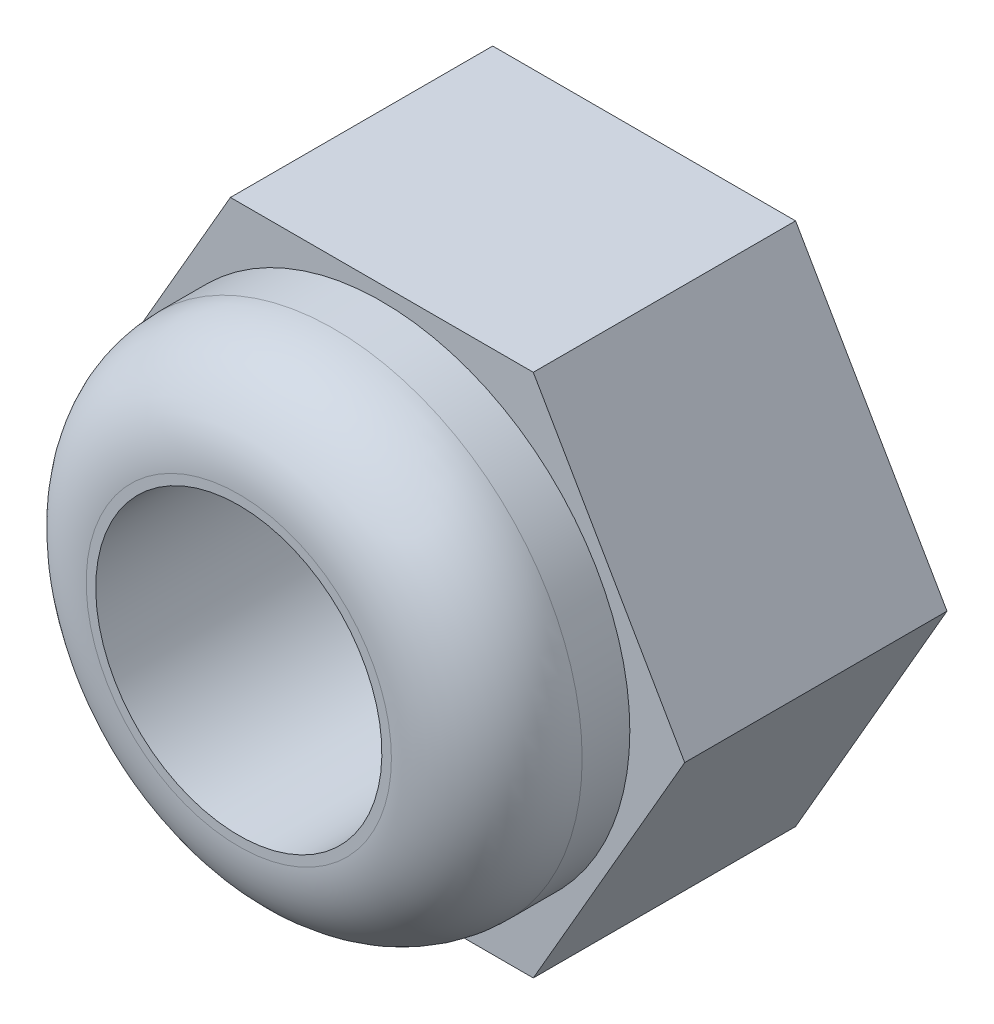
from build123d import *

# Parameters (mm, degrees)
EXTRUDE_1_DEPTH           = 2.75
SKETCH_2_W                = 2.6
SKETCH_2_H                = 1.5
HOLE_WIZARD_3_0_3_1_D     = 3
HOLE_WIZARD_3_0_3_1_DEPTH = 4.25
FILLET_1_R                = 1


with BuildPart() as part:
    # 草图1 → 凸台-拉伸1 (new body)
    with BuildSketch(Plane.XY.offset(2.75)):
        Polygon((1.58771324, -2.75), (3.175426481, 0), (1.58771324, 2.75), (-1.58771324, 2.75), (-3.175426481, 0), (-1.58771324, -2.75), align=None)
    extrude(amount=-EXTRUDE_1_DEPTH)

    # 草图2 → 旋转1 (revolve)
    with BuildSketch(Plane(origin=(0, 0, 0), x_dir=(1, 0, 0), z_dir=(0, 1, 0))):
        with Locations((1.3, -3.5)):
            Rectangle(SKETCH_2_W, SKETCH_2_H)
    revolve(axis=Axis((0, 0, 2.75), (0, 0, 1)))

    # Ø3.0 (3) 直径孔1
    with Locations(Plane(origin=(0, 0, 0), x_dir=(-1, 0, 0), z_dir=(0, 0, -1))):
        with Locations((0, 0)):
            Hole(HOLE_WIZARD_3_0_3_1_D / 2, depth=HOLE_WIZARD_3_0_3_1_DEPTH)

    # 圆角1
    fillet_1_edges = [part.edges().sort_by_distance(p)[0] for p in [
        (-2.6, 0, 4.25),
    ]]
    fillet(fillet_1_edges, radius=FILLET_1_R)


solid = part.part
